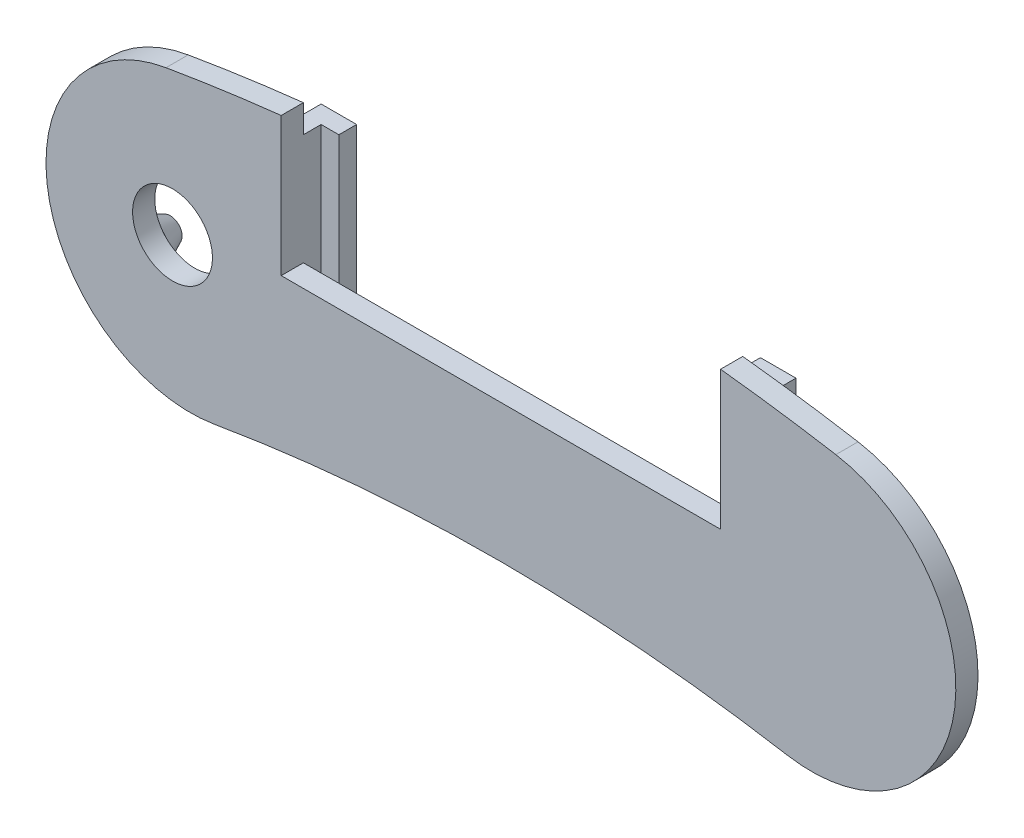
from build123d import *

# Parameters (mm, degrees)
BOSS_EXTRU_1_DEPTH           = 5
ESQUISSE14_W                 = 99.024162062
ESQUISSE14_H                 = 34
ENL_V_MAT_EXTRU_3_DEPTH      = 10
ESQUISSE15_W                 = 4
ESQUISSE15_H                 = 55
BOSS_EXTRU_2_DEPTH           = 8
ESQUISSE16_W                 = 4
ESQUISSE16_H                 = 55
BOSS_EXTRU_3_DEPTH           = 4
ESQUISSE17_W                 = 4
ESQUISSE17_H                 = 55
BOSS_EXTRU_4_DEPTH           = 4
ESQUISSE18_R                 = 5
BOSS_EXTRU_5_DEPTH           = 5
BOSS_EXTRU_5_DRAFT           = 25
BOSS_EXTRU_5_PROFILE_2_DEPTH = 5
BOSS_EXTRU_5_PROFILE_2_DRAFT = 25
BOSS_EXTRU_5_PROFILE_3_DEPTH = 5
BOSS_EXTRU_5_PROFILE_3_DRAFT = 25
ESQUISSE19_R                 = 9
ENL_V_MAT_EXTRU_4_DEPTH      = 5


with BuildPart() as part:
    # Esquisse3 → Boss.-Extru.1 (new body)
    with BuildSketch(Plane.XY):
        with BuildLine():
            ThreePointArc((75.594209632, 441.104915907), (0.107839882, 447.535495506), (-75.381620177, 441.141295626))
            ThreePointArc((-75.381620177, 441.141295626), (-101.972084627, 403.590452402), (-64.421241404, 376.999987952))
            ThreePointArc((-64.421241404, 376.999987952), (0.092160118, 382.464480398), (64.602920658, 376.968897791))
            ThreePointArc((64.602920658, 376.968897791), (102.166574203, 403.541262362), (75.594209632, 441.104915907))
        make_face()
    extrude(amount=BOSS_EXTRU_1_DEPTH)

    # Esquisse14 → Enlèv. mat.-Extru.3 (cut)
    with BuildSketch(Plane(origin=(0, 0, 0), x_dir=(-1, 0, 0), z_dir=(0, 0, -1))):
        with Locations((-0.090839627, 430.535495506)):
            Rectangle(ESQUISSE14_W, ESQUISSE14_H)
    extrude(amount=-ENL_V_MAT_EXTRU_3_DEPTH, mode=Mode.SUBTRACT)


with BuildPart() as body_2:
    # of the pieces the cut leaves, the one that is kept (enl_v_mat_extru_3_keep)
    add(part.part.solids().sort_by_distance((64.602920658, 376.968897791, 0))[0])

    # Esquisse15 → Boss.-Extru.2 (add)
    with BuildSketch(Plane(origin=(0, 0, 0), x_dir=(-1, 0, 0), z_dir=(0, 0, -1))):
        with Locations((-51.602920658, 411.035495506)):
            Rectangle(ESQUISSE15_W, ESQUISSE15_H)
        with Locations((51.421241404, 411.035495506)):
            Rectangle(ESQUISSE15_W, ESQUISSE15_H)
    extrude(amount=BOSS_EXTRU_2_DEPTH)

    # Esquisse16 → Boss.-Extru.3 (add)
    with BuildSketch(Plane.ZY.offset(-49.602920658)):
        with Locations((-6, 411.035495506)):
            Rectangle(ESQUISSE16_W, ESQUISSE16_H)
    extrude(amount=BOSS_EXTRU_3_DEPTH)

    # Esquisse17 → Boss.-Extru.4 (add)
    with BuildSketch(Plane(origin=(-49.421241404, 0, 0), x_dir=(0, 0, -1), z_dir=(1, 0, 0))):
        with Locations((6, 411.035495506)):
            Rectangle(ESQUISSE17_W, ESQUISSE17_H)
    extrude(amount=BOSS_EXTRU_4_DEPTH)


with BuildPart() as boss_extru_5_tool:
    # Esquisse18 → Boss.-Extru.5 (with draft: the straight prism first)
    with BuildSketch(Plane(origin=(0, 0, 0), x_dir=(-1, 0, 0), z_dir=(0, 0, -1))):
        with Locations((63.421241404, 400.070641789)):
            Circle(ESQUISSE18_R)
    extrude(amount=BOSS_EXTRU_5_DEPTH)
    # Boss.-Extru.5: the draft: its side faces are tilted about the plane it starts from
    boss_extru_5_sides = [boss_extru_5_tool.faces().sort_by_distance(p)[0] for p in [
        (-58.421241404, 400.070641789, -2.5),
    ]]
    draft(boss_extru_5_sides, Plane(origin=(0, 0, 0), x_dir=(-1, 0, 0), z_dir=(0, 0, -1)), BOSS_EXTRU_5_DRAFT)


with BuildPart() as body_2_1:
    add(body_2.part)

    # Boss.-Extru.5: add boss_extru_5_tool
    add(boss_extru_5_tool.part)


with BuildPart() as boss_extru_5_profile_2_tool:
    # Esquisse18 → Boss.-Extru.5 profile 2 (with draft: the straight prism first)
    with BuildSketch(Plane(origin=(0, 0, 0), x_dir=(-1, 0, 0), z_dir=(0, 0, -1))):
        with Locations((84.421241404, 400.070641789)):
            Circle(ESQUISSE18_R)
    extrude(amount=BOSS_EXTRU_5_PROFILE_2_DEPTH)
    # Boss.-Extru.5 profile 2: the draft: its side faces are tilted about the plane it starts from
    boss_extru_5_profile_2_sides = [boss_extru_5_profile_2_tool.faces().sort_by_distance(p)[0] for p in [
        (-79.421241404, 400.070641789, -2.5),
    ]]
    draft(boss_extru_5_profile_2_sides, Plane(origin=(0, 0, 0), x_dir=(-1, 0, 0), z_dir=(0, 0, -1)), BOSS_EXTRU_5_PROFILE_2_DRAFT)


with BuildPart() as body_2_2:
    add(body_2_1.part)

    # Boss.-Extru.5 profile 2: add boss_extru_5_profile_2_tool
    add(boss_extru_5_profile_2_tool.part)


with BuildPart() as boss_extru_5_profile_3_tool:
    # Esquisse18 → Boss.-Extru.5 profile 3 (with draft: the straight prism first)
    with BuildSketch(Plane(origin=(0, 0, 0), x_dir=(-1, 0, 0), z_dir=(0, 0, -1))):
        with Locations((73.921241404, 429.238260821)):
            Circle(ESQUISSE18_R)
    extrude(amount=BOSS_EXTRU_5_PROFILE_3_DEPTH)
    # Boss.-Extru.5 profile 3: the draft: its side faces are tilted about the plane it starts from
    boss_extru_5_profile_3_sides = [boss_extru_5_profile_3_tool.faces().sort_by_distance(p)[0] for p in [
        (-68.921241404, 429.238260821, -2.5),
    ]]
    draft(boss_extru_5_profile_3_sides, Plane(origin=(0, 0, 0), x_dir=(-1, 0, 0), z_dir=(0, 0, -1)), BOSS_EXTRU_5_PROFILE_3_DRAFT)


with BuildPart() as body_2_3:
    add(body_2_2.part)

    # Boss.-Extru.5 profile 3: add boss_extru_5_profile_3_tool
    add(boss_extru_5_profile_3_tool.part)

    # Esquisse19 → Enlèv. mat.-Extru.4 (cut)
    with BuildSketch(Plane(origin=(0, 0, 0), x_dir=(-1, 0, 0), z_dir=(0, 0, -1))):
        with Locations((73.921241404, 409.238260821)):
            Circle(ESQUISSE19_R)
    extrude(amount=-ENL_V_MAT_EXTRU_4_DEPTH, mode=Mode.SUBTRACT)


solid = body_2_3.part
